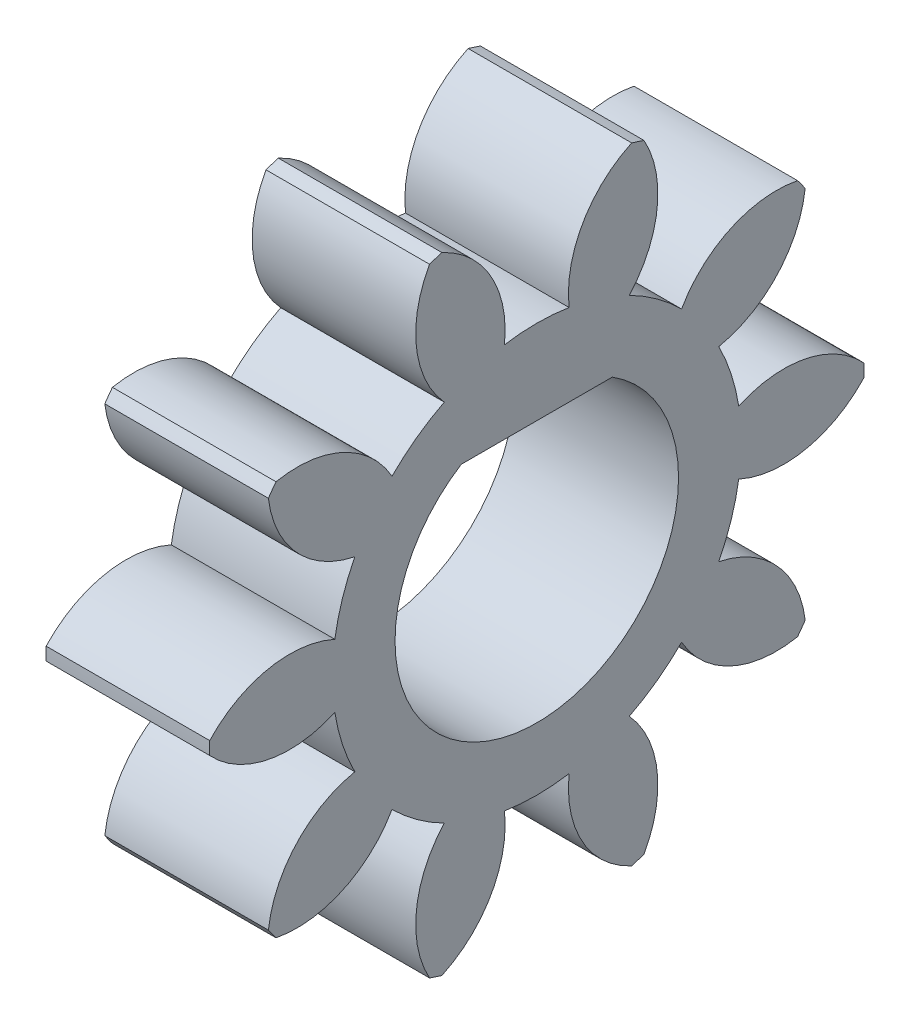
from build123d import *

# Parameters (mm, degrees)
BASPROSKE_W         = 10
BASPROSKE_H         = 6
TOOTHCUT_DEPTH      = 14.114877049
TEETHCUTS_COUNT     = 10
TEETHCUTS_ANGLE     = 324
BORSKE_R            = 2.5
BORE_DEPTH          = 50.0000508
SKETCH1_R           = 2.5
BOSS_EXTRUDE1_DEPTH = 10
CUT_EXTRUDE2_DEPTH  = 10
CUT_EXTRUDE4_DEPTH  = 12.8
CUT_EXTRUDE5_DEPTH  = 7


with BuildPart() as part:
    # BasProSke → Base-Revolve (revolve)
    with BuildSketch(Plane(origin=(0, 0, 0), x_dir=(1, 0, 0), z_dir=(0, 1, 0)), mode=Mode.PRIVATE) as base_revolve_sk:
        with Locations((5, 3)):
            Rectangle(BASPROSKE_W, BASPROSKE_H)
    revolve(base_revolve_sk.sketch.rotate(Axis((-10, 0, 0), (1, 0, 0)), 180), axis=Axis((-10, 0, 0), (1, 0, 0)))

    # TooCutSke → ToothCut (cut, through all)
    with BuildSketch(Plane(origin=(0, 0, 0), x_dir=(0, 0, -1), z_dir=(1, 0, 0))):
        with BuildLine():
            ThreePointArc((0.59278292, 3.701838653), (0, 3.749), (-0.59278292, 3.701838653))
            ThreePointArc((-0.59278292, 3.701838653), (-0.846593509, 4.924114224), (-1.775771316, 5.757784417))
            ThreePointArc((-1.775771316, 5.757784417), (0, 6.0254), (1.775771316, 5.757784417))
            ThreePointArc((1.775771316, 5.757784417), (0.846593509, 4.924114224), (0.59278292, 3.701838653))
        make_face()
    toothcut = extrude(amount=TOOTHCUT_DEPTH, mode=Mode.SUBTRACT)

    # TeethCuts: ToothCut ×10 about axis
    teethcuts_axis = Axis((-10, 0, 0), (1, 0, 0))
    for i in range(1, TEETHCUTS_COUNT):
        add(toothcut.rotate(teethcuts_axis, i * TEETHCUTS_ANGLE / (TEETHCUTS_COUNT - 1)), mode=Mode.SUBTRACT)

    # BorSke → Bore (cut, symmetric)
    with BuildSketch(Plane(origin=(0, 0, 0), x_dir=(0, 0, -1), z_dir=(1, 0, 0))):
        with Locations(Location((0, 0, 0), (0, 0, 180))):
            Circle(BORSKE_R)
    extrude(amount=BORE_DEPTH, both=True, mode=Mode.SUBTRACT)

    # Sketch1 → Boss-Extrude1 (add)
    with BuildSketch(Plane(origin=(10, 0, 0), x_dir=(0, 0, -1), z_dir=(1, 0, 0))):
        Circle(SKETCH1_R)
    extrude(amount=-BOSS_EXTRUDE1_DEPTH)

    # Sketch2 → Cut-Extrude2 (cut)
    with BuildSketch(Plane.ZY):
        with BuildLine():
            Line((1.187434209, 2.2), (-1.187434209, 2.2))
            ThreePointArc((-1.187434209, 2.2), (-1.280900948, -2.146926352), (2.5, 0))
            ThreePointArc((2.5, 0), (2.146926352, 1.280900948), (1.187434209, 2.2))
        make_face()
    extrude(amount=-CUT_EXTRUDE2_DEPTH, mode=Mode.SUBTRACT)

    # Sketch3 → Cut-Extrude4 (cut)
    with BuildSketch(Plane.ZY):
        with BuildLine():
            ThreePointArc((-1.385640646, 2.2), (0, -2.6), (1.385640646, 2.2))
            Line((1.385640646, 2.2), (-1.385640646, 2.2))
        make_face()
    extrude(amount=-CUT_EXTRUDE4_DEPTH, mode=Mode.SUBTRACT)

    # Sketch4 → Cut-Extrude5 (cut)
    with BuildSketch(Plane(origin=(10, 0, 0), x_dir=(0, 0, -1), z_dir=(1, 0, 0))):
        with BuildLine():
            ThreePointArc((5.99882193, 0.11889261), (4.925863873, 0.720361677), (3.703837769, 0.580160996))
            ThreePointArc((3.703837769, 0.580160996), (3.56551088, 1.158504712), (3.337477777, 1.707701113))
            ThreePointArc((3.337477777, 1.707701113), (4.408525556, 2.3125653), (4.92303221, 3.429832919))
            ThreePointArc((4.92303221, 3.429832919), (4.854101966, 3.526711514), (4.783265565, 3.622205204))
            ThreePointArc((4.783265565, 3.622205204), (3.561689615, 3.478134978), (2.655457622, 2.646421322))
            ThreePointArc((2.655457622, 2.646421322), (2.203606911, 3.033004712), (1.69631471, 3.343279438))
            ThreePointArc((1.69631471, 3.343279438), (2.207280316, 4.462170935), (1.966811514, 5.668478849))
            ThreePointArc((1.966811514, 5.668478849), (1.854101966, 5.706339098), (1.740664331, 5.741958524))
            ThreePointArc((1.740664331, 5.741958524), (0.837070982, 4.907378935), (0.59278292, 3.701838653))
            ThreePointArc((0.59278292, 3.701838653), (0, 3.749), (-0.59278292, 3.701838653))
            ThreePointArc((-0.59278292, 3.701838653), (-0.837070982, 4.907378935), (-1.740664331, 5.741958524))
            ThreePointArc((-1.740664331, 5.741958524), (-1.854101966, 5.706339098), (-1.966811514, 5.668478849))
            ThreePointArc((-1.966811514, 5.668478849), (-2.207280316, 4.462170935), (-1.69631471, 3.343279438))
            ThreePointArc((-1.69631471, 3.343279438), (-2.203606911, 3.033004712), (-2.655457622, 2.646421322))
            ThreePointArc((-2.655457622, 2.646421322), (-3.561689615, 3.478134978), (-4.783265565, 3.622205204))
            ThreePointArc((-4.783265565, 3.622205204), (-4.854101966, 3.526711514), (-4.92303221, 3.429832919))
            ThreePointArc((-4.92303221, 3.429832919), (-4.408525556, 2.3125653), (-3.337477777, 1.707701113))
            ThreePointArc((-3.337477777, 1.707701113), (-3.56551088, 1.158504712), (-3.703837769, 0.580160996))
            ThreePointArc((-3.703837769, 0.580160996), (-4.925863873, 0.720361677), (-5.99882193, 0.11889261))
            ThreePointArc((-5.99882193, 0.11889261), (-6, 0), (-5.99882193, -0.11889261))
            ThreePointArc((-5.99882193, -0.11889261), (-4.925863873, -0.720361677), (-3.703837769, -0.580160996))
            ThreePointArc((-3.703837769, -0.580160996), (-3.56551088, -1.158504712), (-3.337477777, -1.707701113))
            ThreePointArc((-3.337477777, -1.707701113), (-4.408525556, -2.3125653), (-4.92303221, -3.429832919))
            ThreePointArc((-4.92303221, -3.429832919), (-4.854101966, -3.526711514), (-4.783265565, -3.622205204))
            ThreePointArc((-4.783265565, -3.622205204), (-3.561689615, -3.478134978), (-2.655457622, -2.646421322))
            ThreePointArc((-2.655457622, -2.646421322), (-2.203606911, -3.033004712), (-1.69631471, -3.343279438))
            ThreePointArc((-1.69631471, -3.343279438), (-2.207280316, -4.462170935), (-1.966811514, -5.668478849))
            ThreePointArc((-1.966811514, -5.668478849), (-1.854101966, -5.706339098), (-1.740664331, -5.741958524))
            ThreePointArc((-1.740664331, -5.741958524), (-0.837070982, -4.907378935), (-0.59278292, -3.701838653))
            ThreePointArc((-0.59278292, -3.701838653), (0, -3.749), (0.59278292, -3.701838653))
            ThreePointArc((0.59278292, -3.701838653), (0.837070982, -4.907378935), (1.740664331, -5.741958524))
            ThreePointArc((1.740664331, -5.741958524), (1.854101966, -5.706339098), (1.966811514, -5.668478849))
            ThreePointArc((1.966811514, -5.668478849), (2.207280316, -4.462170935), (1.69631471, -3.343279438))
            ThreePointArc((1.69631471, -3.343279438), (2.203606911, -3.033004712), (2.655457622, -2.646421322))
            ThreePointArc((2.655457622, -2.646421322), (3.561689615, -3.478134978), (4.783265565, -3.622205204))
            ThreePointArc((4.783265565, -3.622205204), (4.854101966, -3.526711514), (4.92303221, -3.429832919))
            ThreePointArc((4.92303221, -3.429832919), (4.408525556, -2.3125653), (3.337477777, -1.707701113))
            ThreePointArc((3.337477777, -1.707701113), (3.56551088, -1.158504712), (3.703837769, -0.580160996))
            ThreePointArc((3.703837769, -0.580160996), (4.925863873, -0.720361677), (5.99882193, -0.11889261))
            ThreePointArc((5.99882193, -0.11889261), (6, 0), (5.99882193, 0.11889261))
        make_face()
    extrude(amount=-CUT_EXTRUDE5_DEPTH, mode=Mode.SUBTRACT)


solid = part.part
